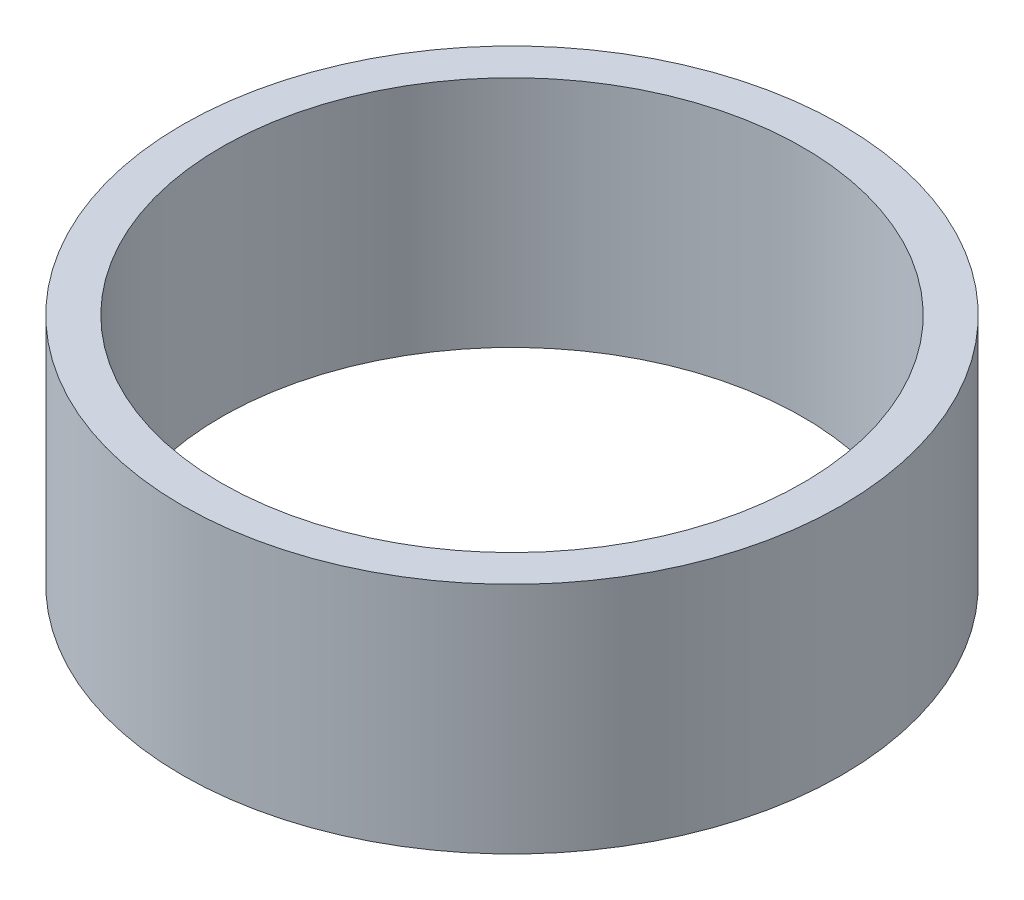
from build123d import *

# Parameters (mm, degrees)
SKETCH1_R           = 42.35
SKETCH1_R_2         = 37.35
BOSS_EXTRUDE1_DEPTH = 30


with BuildPart() as part:
    # Sketch1 → Boss-Extrude1 (new body)
    with BuildSketch(Plane(origin=(0, 0, 0), x_dir=(1, 0, 0), z_dir=(0, 1, 0))):
        Circle(SKETCH1_R)
        Circle(SKETCH1_R_2, mode=Mode.SUBTRACT)
    extrude(amount=BOSS_EXTRUDE1_DEPTH)


solid = part.part
